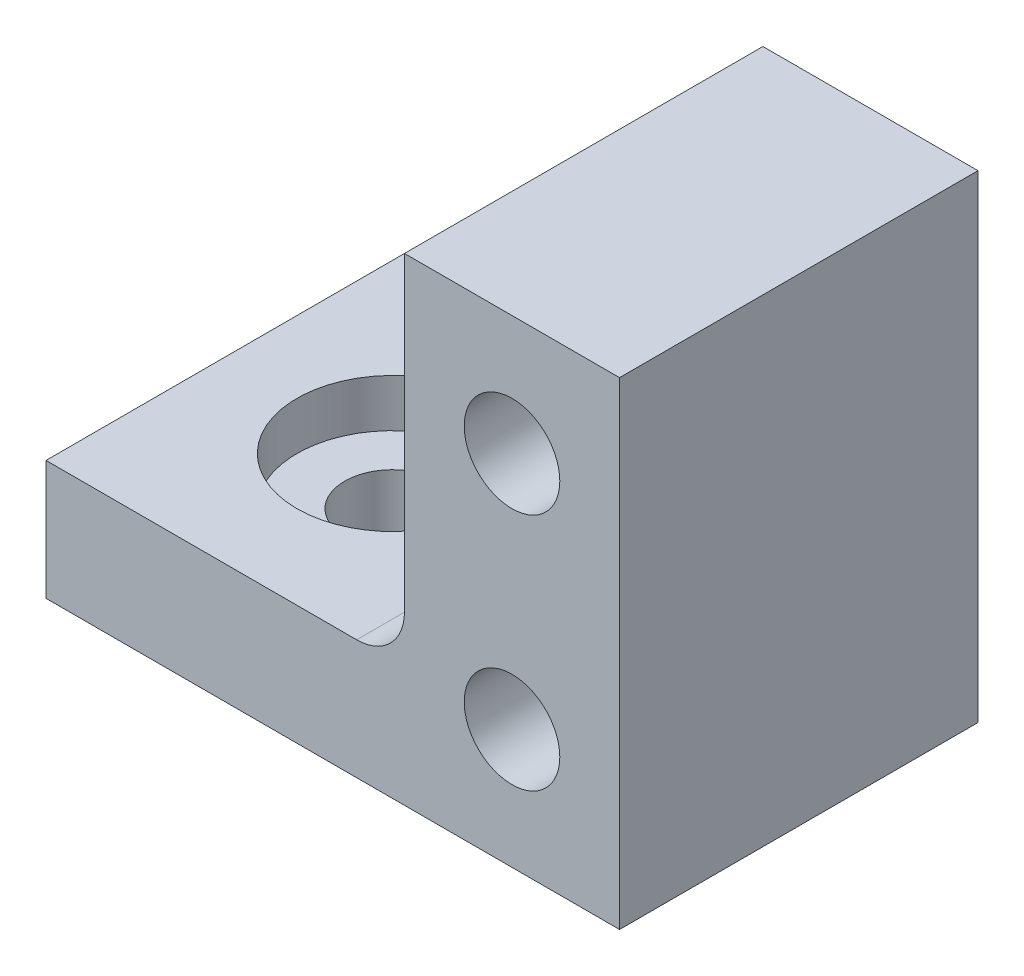
from build123d import *

# Parameters (mm, degrees)
SKETCH1_W           = 24
SKETCH1_H           = 15
BOSS_EXTRUDE2_DEPTH = 5
SKETCH8_W           = 9
SKETCH8_H           = 15
BOSS_EXTRUDE3_DEPTH = 15
CUT_EXTRUDE3_REACH  = 7
SKETCH10_R          = 2
SKETCH9_R           = 4
CUT_EXTRUDE4_DEPTH  = 2
CUT_EXTRUDE5_REACH  = 17
SKETCH11_R          = 2
FILLET4_R           = 2


with BuildPart() as part:
    # Sketch1 → Boss-Extrude2 (new body)
    with BuildSketch(Plane(origin=(0, 0, 0), x_dir=(1, 0, 0), z_dir=(0, 1, 0))):
        Rectangle(SKETCH1_W, SKETCH1_H)
    extrude(amount=BOSS_EXTRUDE2_DEPTH)

    # Sketch8 → Boss-Extrude3 (add)
    with BuildSketch(Plane(origin=(0, 5, 0), x_dir=(1, 0, 0), z_dir=(0, 1, 0))):
        with Locations((7.5, 0)):
            Rectangle(SKETCH8_W, SKETCH8_H)
    extrude(amount=BOSS_EXTRUDE3_DEPTH)

    # Sketch10 → Cut-Extrude3 (cut, up to next)
    with BuildSketch(Plane(origin=(0, 5, 0), x_dir=(1, 0, 0), z_dir=(0, 1, 0)), mode=Mode.PRIVATE) as cut_extrude3_sk1:
        with Locations((-5, 0)):
            Circle(SKETCH10_R)
    cut_extrude3_tool1 = extrude(cut_extrude3_sk1.sketch, amount=-CUT_EXTRUDE3_REACH, mode=Mode.PRIVATE) & part.part
    add(cut_extrude3_tool1.solids().sort_by_distance((-5, 5, 0))[0], mode=Mode.SUBTRACT)

    # Sketch9 → Cut-Extrude4 (cut)
    with BuildSketch(Plane(origin=(0, 5, 0), x_dir=(1, 0, 0), z_dir=(0, 1, 0))):
        with Locations((-5, 0)):
            Circle(SKETCH9_R)
    extrude(amount=-CUT_EXTRUDE4_DEPTH, mode=Mode.SUBTRACT)

    # Sketch11 → Cut-Extrude5 (cut, up to next)
    with BuildSketch(Plane.XY.offset(7.5), mode=Mode.PRIVATE) as cut_extrude5_sk1:
        with Locations((7.5, 15)):
            Circle(SKETCH11_R)
    cut_extrude5_tool1 = extrude(cut_extrude5_sk1.sketch, amount=-CUT_EXTRUDE5_REACH, mode=Mode.PRIVATE) & part.part
    add(cut_extrude5_tool1.solids().sort_by_distance((7.5, 15, 7.5))[0], mode=Mode.SUBTRACT)
    # Sketch11 → Cut-Extrude5 (cut, up to next)
    with BuildSketch(Plane.XY.offset(7.5), mode=Mode.PRIVATE) as cut_extrude5_sk2:
        with Locations((7.5, 5)):
            Circle(SKETCH11_R)
    cut_extrude5_tool2 = extrude(cut_extrude5_sk2.sketch, amount=-CUT_EXTRUDE5_REACH, mode=Mode.PRIVATE) & part.part
    add(cut_extrude5_tool2.solids().sort_by_distance((7.5, 5, 7.5))[0], mode=Mode.SUBTRACT)

    # Fillet4
    fillet4_edges = [part.edges().sort_by_distance(p)[0] for p in [
        (3, 5, 0),
    ]]
    fillet(fillet4_edges, radius=FILLET4_R)


solid = part.part
